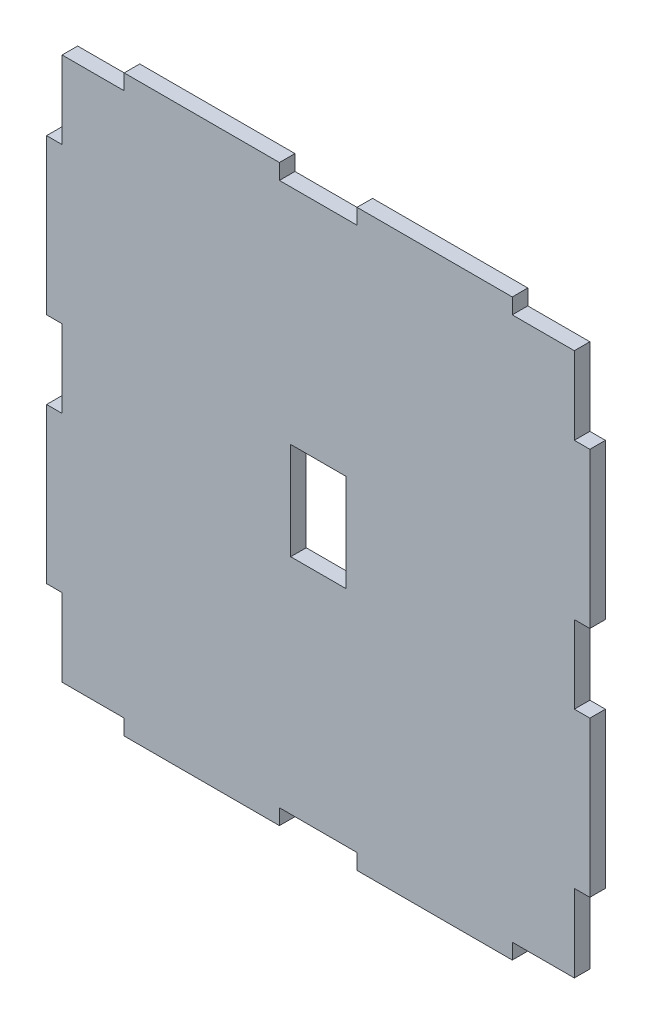
from build123d import *

# Parameters (mm, degrees)
SKETCH1_W           = 66
SKETCH1_H           = 70
BOSS_EXTRUDE1_DEPTH = 2
SKETCH2_W           = 2
SKETCH2_H           = 20
BOSS_EXTRUDE2_DEPTH = 2
SKETCH3_W           = 20
SKETCH3_H           = 2
BOSS_EXTRUDE3_DEPTH = 2
SKETCH4_W           = 7.1
SKETCH4_H           = 12.53
CUT_EXTRUDE1_DEPTH  = 10


with BuildPart() as part:
    # Sketch1 → Boss-Extrude1 (new body)
    with BuildSketch(Plane.XY):
        Rectangle(SKETCH1_W, SKETCH1_H)
    extrude(amount=BOSS_EXTRUDE1_DEPTH)

    # Sketch2 → Boss-Extrude2 (add)
    with BuildSketch(Plane(origin=(0, 0, 0), x_dir=(-1, 0, 0), z_dir=(0, 0, -1))):
        with Locations((34, -15)):
            Rectangle(SKETCH2_W, SKETCH2_H)
        with Locations((34, 15)):
            Rectangle(SKETCH2_W, SKETCH2_H)
        with Locations((-34, -15)):
            Rectangle(SKETCH2_W, SKETCH2_H)
        with Locations((-34, 15)):
            Rectangle(SKETCH2_W, SKETCH2_H)
    extrude(amount=-BOSS_EXTRUDE2_DEPTH)

    # Sketch3 → Boss-Extrude3 (add)
    with BuildSketch(Plane(origin=(0, 0, 0), x_dir=(-1, 0, 0), z_dir=(0, 0, -1))):
        with Locations((-15, 36)):
            Rectangle(SKETCH3_W, SKETCH3_H)
        with Locations((15, 36)):
            Rectangle(SKETCH3_W, SKETCH3_H)
        with Locations((-15, -36)):
            Rectangle(SKETCH3_W, SKETCH3_H)
        with Locations((15, -36)):
            Rectangle(SKETCH3_W, SKETCH3_H)
    extrude(amount=-BOSS_EXTRUDE3_DEPTH)

    # Sketch4 → Cut-Extrude1 (cut)
    with BuildSketch(Plane(origin=(0, 0, 0), x_dir=(-1, 0, 0), z_dir=(0, 0, -1))):
        Rectangle(SKETCH4_W, SKETCH4_H)
    extrude(amount=-CUT_EXTRUDE1_DEPTH, mode=Mode.SUBTRACT)


solid = part.part
